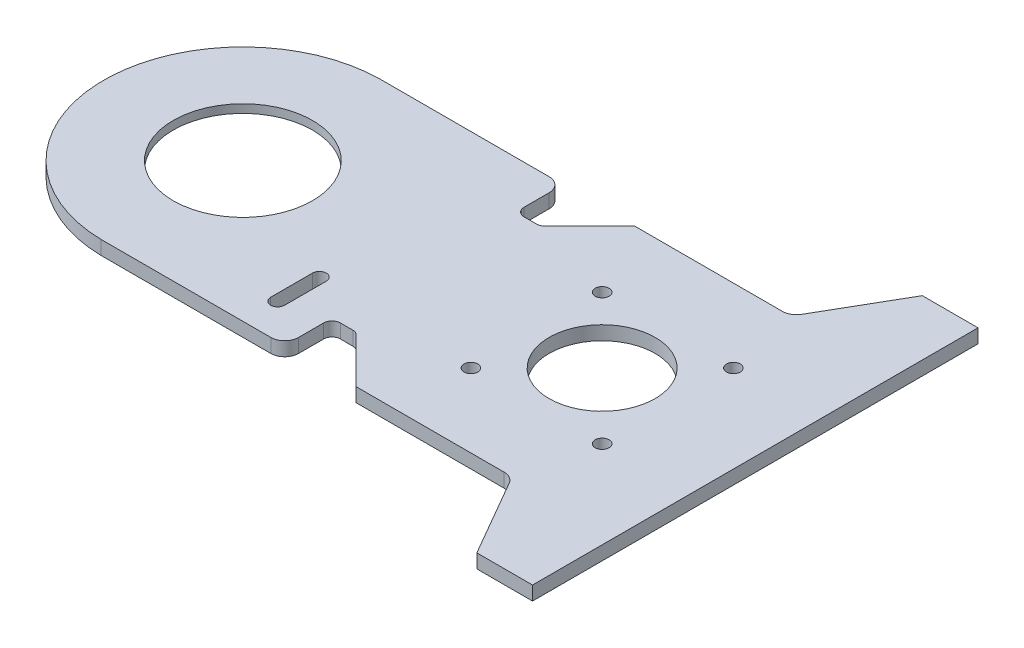
from build123d import *

# Parameters (mm, degrees)
BOSS_EXTRUDE1_DEPTH = 5
SKETCH10_R          = 19.05
SKETCH10_R_2        = 2.5
SKETCH10_R_3        = 25
CUT_EXTRUDE7_DEPTH  = 157.385136652
SKETCH11_R          = 31
CUT_EXTRUDE8_DEPTH  = 2
CUT_EXTRUDE9_DEPTH  = 157.385136652


with BuildPart() as part:
    # Sketch1 → Boss-Extrude1 (new body)
    with BuildSketch(Plane(origin=(0, 0, 0), x_dir=(1, 0, 0), z_dir=(0, 1, 0))):
        with BuildLine():
            Line((15.254575611, 35.990242765), (15.254575611, 44.990242765))
            ThreePointArc((15.254575611, 44.990242765), (13.790109517, 48.525776671), (10.254575611, 49.990242765))
            Line((10.254575611, 49.990242765), (-50.745424389, 49.990242765))
            ThreePointArc((-50.745424389, 49.990242765), (-99.757685432, 0), (-50.745424389, -49.990242765))
            Line((-50.745424389, -49.990242765), (10.254575611, -49.990242765))
            ThreePointArc((10.254575611, -49.990242765), (13.790109517, -48.525776671), (15.254575611, -44.990242765))
            Line((15.254575611, -44.990242765), (15.254575611, -35.990242765))
            ThreePointArc((15.254575611, -35.990242765), (16.133255268, -33.868922422), (18.254575611, -32.990242765))
            Line((18.254575611, -32.990242765), (22.711934924, -32.990242765))
            ThreePointArc((22.711934924, -32.990242765), (23.859985221, -33.218604168), (24.833255268, -33.868922422))
            Line((24.833255268, -33.868922422), (40.954575611, -49.990242765))
            Line((40.954575611, -49.990242765), (50.745424389, -49.990242765))
            Line((50.745424389, -49.990242765), (94.067824265, -49.990242765))
            ThreePointArc((94.067824265, -49.990242765), (96.567824265, -50.660115747), (98.397951284, -52.490242765))
            Line((98.397951284, -52.490242765), (114.280717029, -80))
            Line((114.280717029, -80), (134.280717029, -80))
            Line((134.280717029, -80), (134.280717029, 80))
            Line((134.280717029, 80), (114.280717029, 80))
            Line((114.280717029, 80), (98.397951284, 52.490242765))
            ThreePointArc((98.397951284, 52.490242765), (96.567824265, 50.660115747), (94.067824265, 49.990242765))
            Line((94.067824265, 49.990242765), (50.745424389, 49.990242765))
            Line((50.745424389, 49.990242765), (40.954575611, 49.990242765))
            Line((40.954575611, 49.990242765), (24.833255268, 33.868922422))
            ThreePointArc((24.833255268, 33.868922422), (23.859985221, 33.218604168), (22.711934924, 32.990242765))
            Line((22.711934924, 32.990242765), (18.254575611, 32.990242765))
            ThreePointArc((18.254575611, 32.990242765), (16.133255268, 33.868922422), (15.254575611, 35.990242765))
        make_face()
    extrude(amount=BOSS_EXTRUDE1_DEPTH)

    # Sketch10 → Cut-Extrude7 (cut, through all)
    with BuildSketch(Plane(origin=(0, 5, 0), x_dir=(1, 0, 0), z_dir=(0, 1, 0))):
        with Locations((79.280717029, 0)):
            Circle(SKETCH10_R)
        with Locations((55.710717029, 23.57)):
            Circle(SKETCH10_R_2)
        with Locations((102.850717029, 23.57)):
            Circle(SKETCH10_R_2)
        with Locations((102.850717029, -23.57)):
            Circle(SKETCH10_R_2)
        with Locations((55.710717029, -23.57)):
            Circle(SKETCH10_R_2)
        with Locations((-49.757685432, 0)):
            Circle(SKETCH10_R_3)
    extrude(amount=-CUT_EXTRUDE7_DEPTH, mode=Mode.SUBTRACT)

    # Sketch11 → Cut-Extrude8 (cut)
    with BuildSketch(Plane.XZ):
        with Locations((-49.757685432, 0)):
            Circle(SKETCH11_R)
    extrude(amount=-CUT_EXTRUDE8_DEPTH, mode=Mode.SUBTRACT)

    # Sketch12 → Cut-Extrude9 (cut, through all)
    with BuildSketch(Plane.XZ):
        with BuildLine():
            ThreePointArc((2.742314568, 37.5), (0.242314568, 40), (-2.257685432, 37.5))
            Line((-2.257685432, 37.5), (-2.257685432, 22.5))
            ThreePointArc((-2.257685432, 22.5), (0.242314568, 20), (2.742314568, 22.5))
            Line((2.742314568, 22.5), (2.742314568, 37.5))
        make_face()
    extrude(amount=-CUT_EXTRUDE9_DEPTH, mode=Mode.SUBTRACT)


solid = part.part
